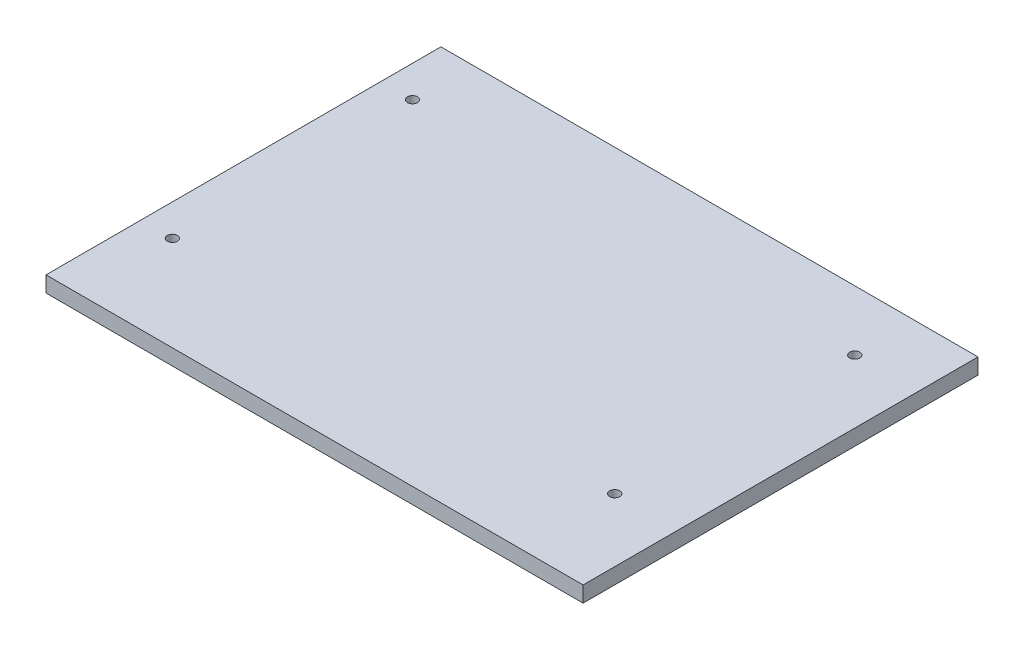
from build123d import *

# Parameters (mm, degrees)
SKETCH1_W           = 170
SKETCH1_H           = 125
SKETCH1_R           = 1.6
BOSS_EXTRUDE1_DEPTH = 5


with BuildPart() as part:
    # Sketch1 → Boss-Extrude1 (new body)
    with BuildSketch(Plane(origin=(0, 0, 0), x_dir=(1, 0, 0), z_dir=(0, 1, 0))):
        Rectangle(SKETCH1_W, SKETCH1_H)
        with Locations((-75, 43.5)):
            Circle(SKETCH1_R, mode=Mode.SUBTRACT)
        with Locations((-75, -32.5)):
            Circle(SKETCH1_R, mode=Mode.SUBTRACT)
        with Locations((65, -32.5)):
            Circle(SKETCH1_R, mode=Mode.SUBTRACT)
        with Locations((65, 43.5)):
            Circle(SKETCH1_R, mode=Mode.SUBTRACT)
    extrude(amount=BOSS_EXTRUDE1_DEPTH)


solid = part.part
